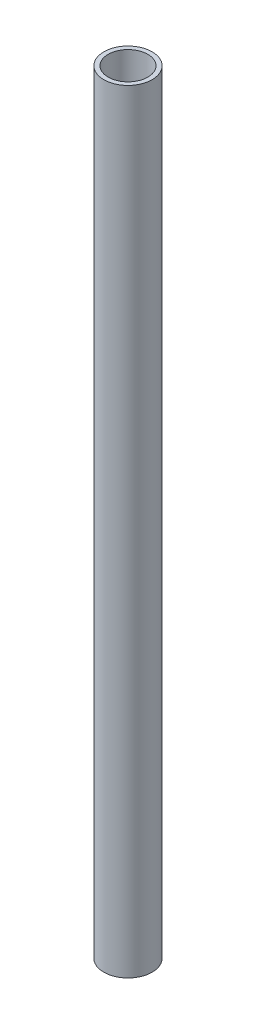
from build123d import *

# Parameters (mm, degrees)
SKETCH1_R           = 12.7
SKETCH1_R_2         = 10.414
BOSS_EXTRUDE1_DEPTH = 406.4


with BuildPart() as part:
    # Sketch1 → Boss-Extrude1 (new body)
    with BuildSketch(Plane(origin=(0, 0, 0), x_dir=(1, 0, 0), z_dir=(0, 1, 0))):
        Circle(SKETCH1_R)
        Circle(SKETCH1_R_2, mode=Mode.SUBTRACT)
    extrude(amount=BOSS_EXTRUDE1_DEPTH)


solid = part.part
